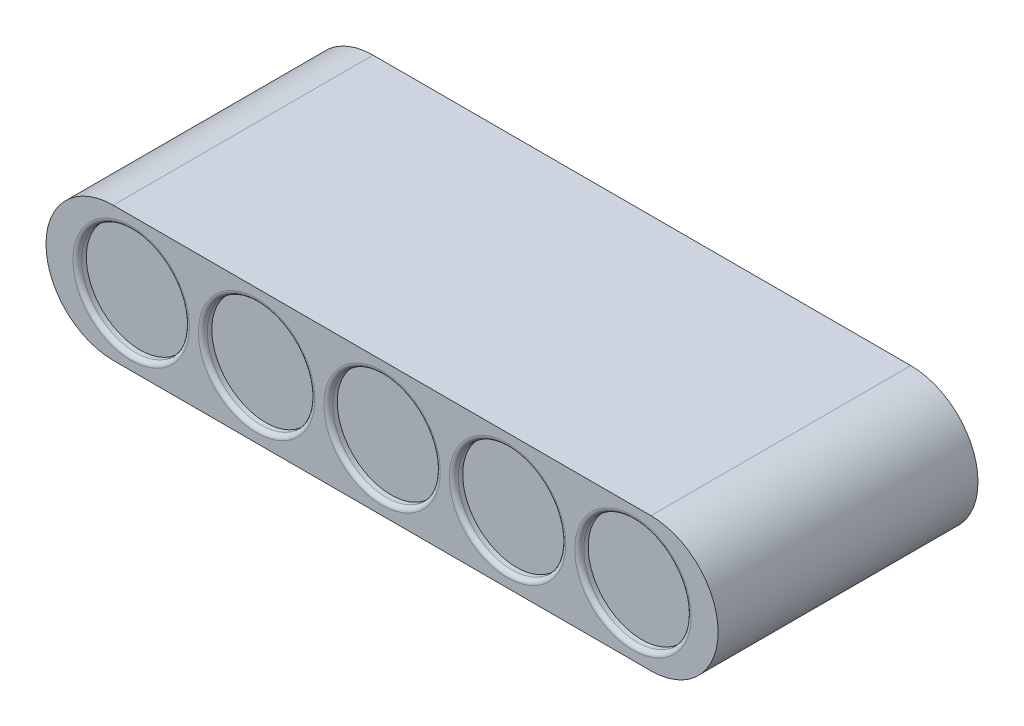
from build123d import *

# Parameters (mm, degrees)
BOSS_EXTRUDE1_DEPTH = 58
SKETCH2_R           = 12
CUT_EXTRUDE1_DEPTH  = 2
FILLET1_R           = 1


with BuildPart() as part:
    # Sketch1 → Boss-Extrude1 (new body)
    with BuildSketch(Plane.XY):
        with BuildLine():
            Line((120, 15), (0, 15))
            ThreePointArc((0, 15), (-15, 0), (0, -15))
            Line((0, -15), (120, -15))
            ThreePointArc((120, -15), (135, 0), (120, 15))
        make_face()
    extrude(amount=BOSS_EXTRUDE1_DEPTH)

    # Sketch2 → Cut-Extrude1 (cut)
    with BuildSketch(Plane.XY.offset(58)):
        with Locations((60, 0)):
            Circle(SKETCH2_R)
        with Locations((88, 0)):
            Circle(SKETCH2_R)
        with Locations((116, 0)):
            Circle(SKETCH2_R)
        with Locations((32, 0)):
            Circle(SKETCH2_R)
        with Locations((4, 0)):
            Circle(SKETCH2_R)
    extrude(amount=-CUT_EXTRUDE1_DEPTH, mode=Mode.SUBTRACT)

    # Fillet1
    fillet1_edges = [part.edges().sort_by_distance(p)[0] for p in [
        (-8, 0, 58),
        (20, 0, 58),
        (104, 0, 58),
        (76, 0, 58),
        (48, 0, 58),
    ]]
    fillet(fillet1_edges, radius=FILLET1_R)


solid = part.part
